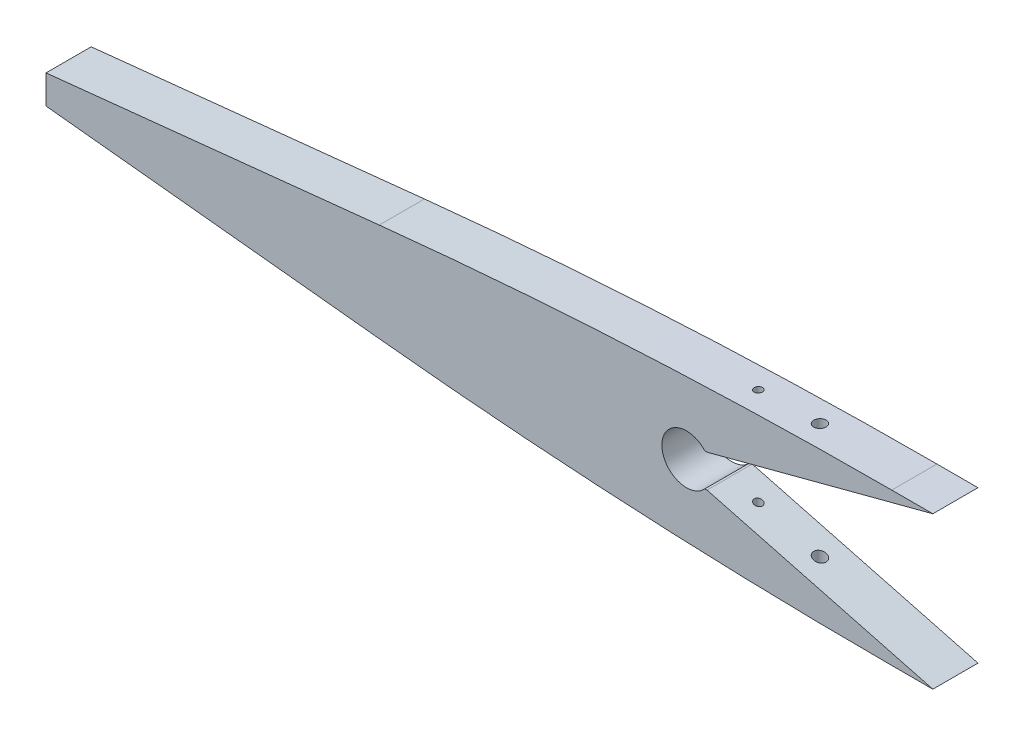
from build123d import *

# Parameters (mm, degrees)
EXTRUDE1_DEPTH          = 5.5
SKETCH2_R               = 1.5
SKETCH2_R_2             = 1
CUT_EXTRUDE1_DEPTH      = 19.5
CUT_EXTRUDE1_DEPTH_BACK = 19.5


with BuildPart() as part:
    # Sketch1 → Extrude1 (new body, symmetric)
    with BuildSketch(Plane.XY):
        with BuildLine():
            Line((-40, 18.5), (-30, 18.5))
            Line((-30, 18.5), (-85, 4))
            Line((-85, 4), (-85.527864045, 4))
            ThreePointArc((-85.527864045, 4), (-96, 0), (-85.527864045, -4))
            Line((-85.527864045, -4), (-85, -4))
            Line((-85, -4), (-30, -18.5))
            Line((-30, -18.5), (-40, -18.5))
            ThreePointArc((-40, -18.5), (-102.498734411, -16.871356549), (-164.827821897, -11.989846995))
            Line((-164.827821897, -11.989846995), (-246, -3.5))
            Line((-246, -3.5), (-246, 3.5))
            Line((-246, 3.5), (-164.827821897, 11.989846995))
            ThreePointArc((-164.827821897, 11.989846995), (-102.498734411, 16.871356549), (-40, 18.5))
        make_face()
    extrude(amount=EXTRUDE1_DEPTH, both=True)

    # Sketch2 → Cut-Extrude1 (cut, two sides)
    with BuildSketch(Plane(origin=(0, 0, 0), x_dir=(1, 0, 0), z_dir=(0, 1, 0))) as cut_extrude1_sk:
        with Locations(Location((-63, 0, 0), (0, 0, 270))):  # turned: the seam where the file's is
            Circle(SKETCH2_R)
        with Locations(Location((-78, 0, 0), (0, 0, 270))):  # turned: the seam where the file's is
            Circle(SKETCH2_R_2)
    extrude(amount=CUT_EXTRUDE1_DEPTH, mode=Mode.SUBTRACT)
    extrude(cut_extrude1_sk.sketch, amount=-CUT_EXTRUDE1_DEPTH_BACK, mode=Mode.SUBTRACT)


solid = part.part
